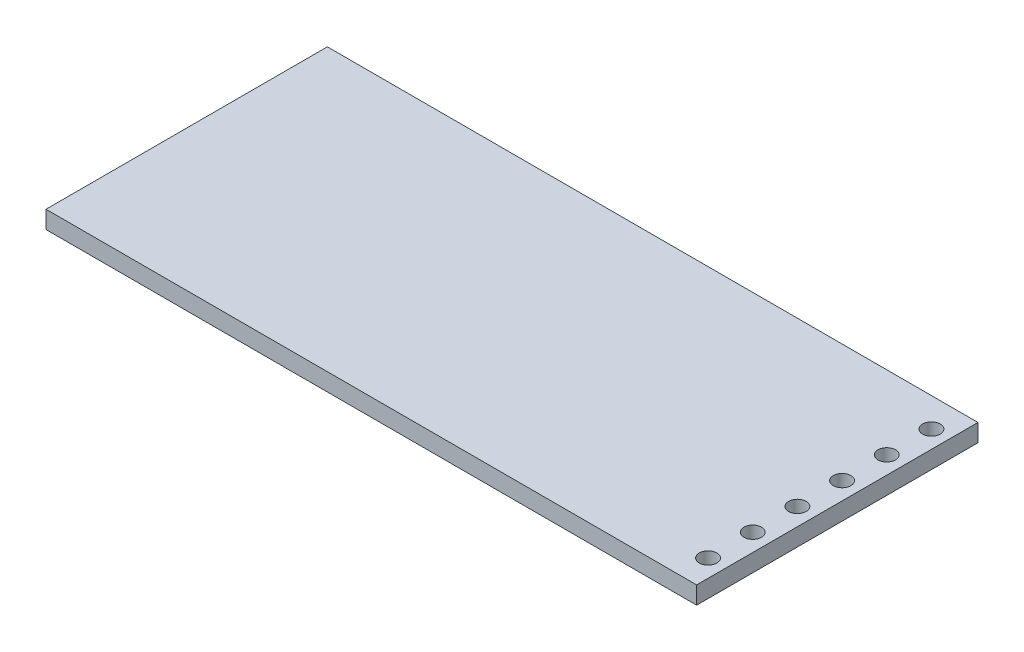
from build123d import *

# Parameters (mm, degrees)
SKETCH1_W           = 37
SKETCH1_H           = 16
BOSS_EXTRUDE1_DEPTH = 1
SKETCH2_R           = 0.5
CUT_EXTRUDE1_DEPTH  = 10


with BuildPart() as part:
    # Sketch1 → Boss-Extrude1 (new body)
    with BuildSketch(Plane(origin=(0, 0, 0), x_dir=(1, 0, 0), z_dir=(0, 1, 0))):
        Rectangle(SKETCH1_W, SKETCH1_H)
    extrude(amount=BOSS_EXTRUDE1_DEPTH)

    # Sketch2 → Cut-Extrude1 (cut)
    with BuildSketch(Plane(origin=(0, 1, 0), x_dir=(1, 0, 0), z_dir=(0, 1, 0))):
        with Locations((17.5, -6.35)):
            Circle(SKETCH2_R)
        with Locations((17.5, -3.81)):
            Circle(SKETCH2_R)
        with Locations((17.5, -1.27)):
            Circle(SKETCH2_R)
        with Locations((17.5, 1.27)):
            Circle(SKETCH2_R)
        with Locations((17.5, 3.81)):
            Circle(SKETCH2_R)
        with Locations((17.5, 6.35)):
            Circle(SKETCH2_R)
    extrude(amount=-CUT_EXTRUDE1_DEPTH, mode=Mode.SUBTRACT)


solid = part.part
